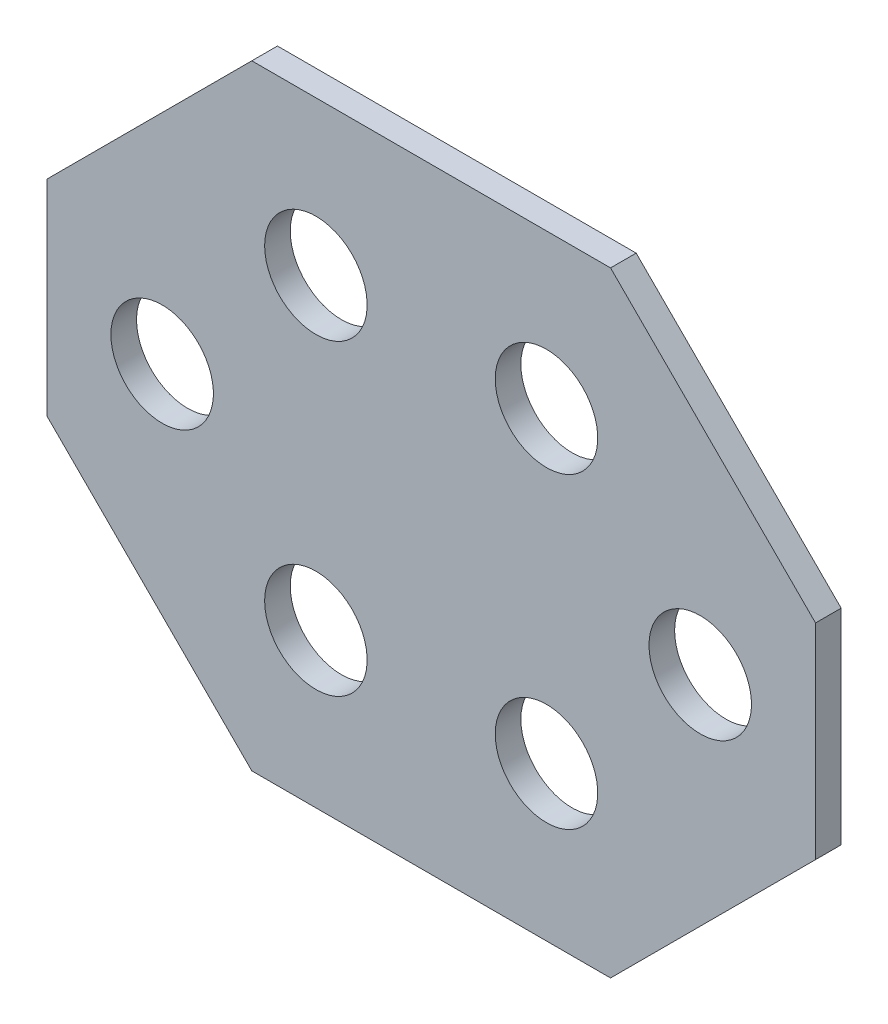
from build123d import *

# Parameters (mm, degrees)
SKETCH1_W           = 30
SKETCH1_H           = 24
BOSS_EXTRUDE1_DEPTH = 1
SKETCH3_R           = 2
CUT_EXTRUDE1_DEPTH  = 3
CHAMFER1_SIZE       = 8


with BuildPart() as part:
    # Sketch1 → Boss-Extrude1 (new body)
    with BuildSketch(Plane.XY):
        Rectangle(SKETCH1_W, SKETCH1_H)
    extrude(amount=BOSS_EXTRUDE1_DEPTH)

    # Sketch3 → Cut-Extrude1 (cut)
    with BuildSketch(Plane(origin=(0, 0, 0), x_dir=(-1, 0, 0), z_dir=(0, 0, -1))):
        with Locations((-4.5, 6)):
            Circle(SKETCH3_R)
        with Locations((-4.5, -6)):
            Circle(SKETCH3_R)
        with Locations((-10.5, 0)):
            Circle(SKETCH3_R)
    cut_extrude1 = extrude(amount=-CUT_EXTRUDE1_DEPTH, mode=Mode.SUBTRACT)

    # Chamfer1
    chamfer1_edges = [part.edges().sort_by_distance(p)[0] for p in [
        (15, -12, 0.5),
        (15, 12, 0.5),
        (-15, 12, 0.5),
        (-15, -12, 0.5),
    ]]
    chamfer(chamfer1_edges, length=CHAMFER1_SIZE)

    # Mirror1: Cut-Extrude1 across plane
    add(cut_extrude1.mirror(Plane(origin=(0, 0, 0), x_dir=(0, 0, 1), z_dir=(1, 0, 0))), mode=Mode.SUBTRACT)


solid = part.part
